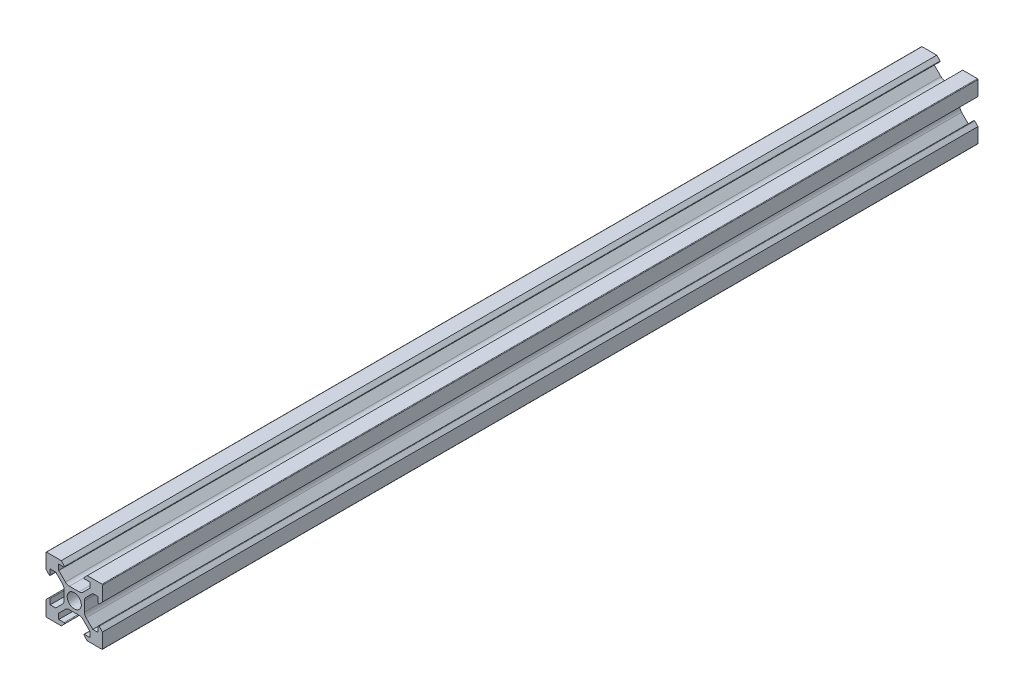
from build123d import *

# Parameters (mm, degrees)
ESBO_O1_R                = 2.5
RESSALTO_EXTRUS_O1_DEPTH = 310


with BuildPart() as part:
    # Esboço1 → Ressalto-extrusão1 (new body)
    with BuildSketch(Plane.XY):
        with BuildLine():
            Line((-4.6, -10), (-9.8, -10))
            ThreePointArc((-9.8, -10), (-9.941421356, -9.941421356), (-10, -9.8))
            Line((-10, -9.8), (-10, -4.6))
            Line((-10, -4.6), (-8.841421356, -3.441421356))
            ThreePointArc((-8.841421356, -3.441421356), (-8.623463314, -3.398066806), (-8.5, -3.582842712))
            Line((-8.5, -3.582842712), (-8.5, -5.5))
            Line((-8.5, -5.5), (-6.560660172, -5.5))
            Line((-6.560660172, -5.5), (-4.185786438, -3.125126266))
            ThreePointArc((-4.185786438, -3.125126266), (-3.752240935, -2.476279568), (-3.6, -1.710912703))
            Line((-3.6, -1.710912703), (-3.6, 1.710912703))
            ThreePointArc((-3.6, 1.710912703), (-3.752240935, 2.476279568), (-4.185786438, 3.125126266))
            Line((-4.185786438, 3.125126266), (-6.560660172, 5.5))
            Line((-6.560660172, 5.5), (-8.5, 5.5))
            Line((-8.5, 5.5), (-8.5, 3.582842712))
            ThreePointArc((-8.5, 3.582842712), (-8.623463314, 3.398066806), (-8.841421356, 3.441421356))
            Line((-8.841421356, 3.441421356), (-10, 4.6))
            Line((-10, 4.6), (-10, 9.8))
            ThreePointArc((-10, 9.8), (-9.941421356, 9.941421356), (-9.8, 10))
            Line((-9.8, 10), (-4.6, 10))
            Line((-4.6, 10), (-3.441421356, 8.841421356))
            ThreePointArc((-3.441421356, 8.841421356), (-3.398066806, 8.623463314), (-3.582842712, 8.5))
            Line((-3.582842712, 8.5), (-5.5, 8.5))
            Line((-5.5, 8.5), (-5.5, 6.560660172))
            Line((-5.5, 6.560660172), (-3.125126266, 4.185786438))
            ThreePointArc((-3.125126266, 4.185786438), (-2.476279568, 3.752240935), (-1.710912703, 3.6))
            Line((-1.710912703, 3.6), (1.710912703, 3.6))
            ThreePointArc((1.710912703, 3.6), (2.476279568, 3.752240935), (3.125126266, 4.185786438))
            Line((3.125126266, 4.185786438), (5.5, 6.560660172))
            Line((5.5, 6.560660172), (5.5, 8.5))
            Line((5.5, 8.5), (3.582842712, 8.5))
            ThreePointArc((3.582842712, 8.5), (3.398066806, 8.623463314), (3.441421356, 8.841421356))
            Line((3.441421356, 8.841421356), (4.6, 10))
            Line((4.6, 10), (9.8, 10))
            ThreePointArc((9.8, 10), (9.941421356, 9.941421356), (10, 9.8))
            Line((10, 9.8), (10, 4.6))
            Line((10, 4.6), (8.841421356, 3.441421356))
            ThreePointArc((8.841421356, 3.441421356), (8.623463314, 3.398066806), (8.5, 3.582842712))
            Line((8.5, 3.582842712), (8.5, 5.5))
            Line((8.5, 5.5), (6.560660172, 5.5))
            Line((6.560660172, 5.5), (4.185786438, 3.125126266))
            ThreePointArc((4.185786438, 3.125126266), (3.752240935, 2.476279568), (3.6, 1.710912703))
            Line((3.6, 1.710912703), (3.6, -1.710912703))
            ThreePointArc((3.6, -1.710912703), (3.752240935, -2.476279568), (4.185786438, -3.125126266))
            Line((4.185786438, -3.125126266), (6.560660172, -5.5))
            Line((6.560660172, -5.5), (8.5, -5.5))
            Line((8.5, -5.5), (8.5, -3.582842712))
            ThreePointArc((8.5, -3.582842712), (8.623463314, -3.398066806), (8.841421356, -3.441421356))
            Line((8.841421356, -3.441421356), (10, -4.6))
            Line((10, -4.6), (10, -9.8))
            ThreePointArc((10, -9.8), (9.941421356, -9.941421356), (9.8, -10))
            Line((9.8, -10), (4.6, -10))
            Line((4.6, -10), (3.441421356, -8.841421356))
            ThreePointArc((3.441421356, -8.841421356), (3.398066806, -8.623463314), (3.582842712, -8.5))
            Line((3.582842712, -8.5), (5.5, -8.5))
            Line((5.5, -8.5), (5.5, -6.560660172))
            Line((5.5, -6.560660172), (3.125126266, -4.185786438))
            ThreePointArc((3.125126266, -4.185786438), (2.476279568, -3.752240935), (1.710912703, -3.6))
            Line((1.710912703, -3.6), (-1.710912703, -3.6))
            ThreePointArc((-1.710912703, -3.6), (-2.476279568, -3.752240935), (-3.125126266, -4.185786438))
            Line((-3.125126266, -4.185786438), (-5.5, -6.560660172))
            Line((-5.5, -6.560660172), (-5.5, -8.5))
            Line((-5.5, -8.5), (-3.582842712, -8.5))
            ThreePointArc((-3.582842712, -8.5), (-3.398066806, -8.623463314), (-3.441421356, -8.841421356))
            Line((-3.441421356, -8.841421356), (-4.6, -10))
        make_face()
        Circle(ESBO_O1_R, mode=Mode.SUBTRACT)
    extrude(amount=RESSALTO_EXTRUS_O1_DEPTH)


solid = part.part
